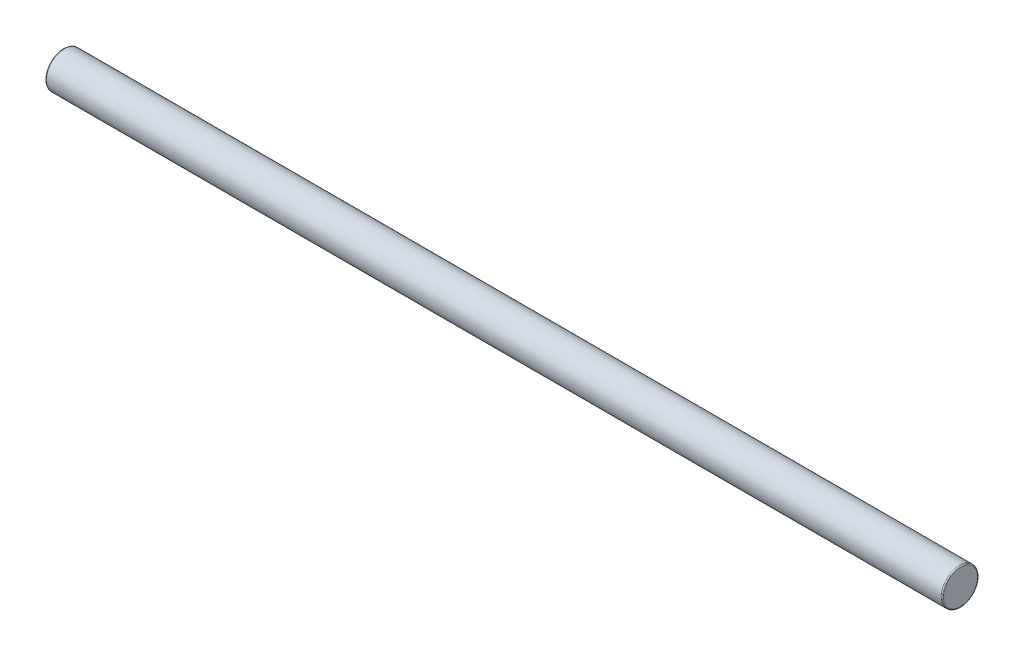
from build123d import *

# Parameters (mm, degrees)
SKETCH1_R      = 0.381
EXTRUDE1_DEPTH = 18.796
FILLET1_R      = 0.0254


with BuildPart() as part:
    # Sketch1 → Extrude1 (new body)
    with BuildSketch(Plane(origin=(0, 0, 0), x_dir=(0, 0, -1), z_dir=(1, 0, 0))):
        Circle(SKETCH1_R)
    extrude(amount=EXTRUDE1_DEPTH)

    # Fillet1
    fillet1_edges = [part.edges().sort_by_distance(p)[0] for p in [
        (0, 0, 0.381),
        (18.796, 0, 0.381),
    ]]
    fillet(fillet1_edges, radius=FILLET1_R)


solid = part.part
